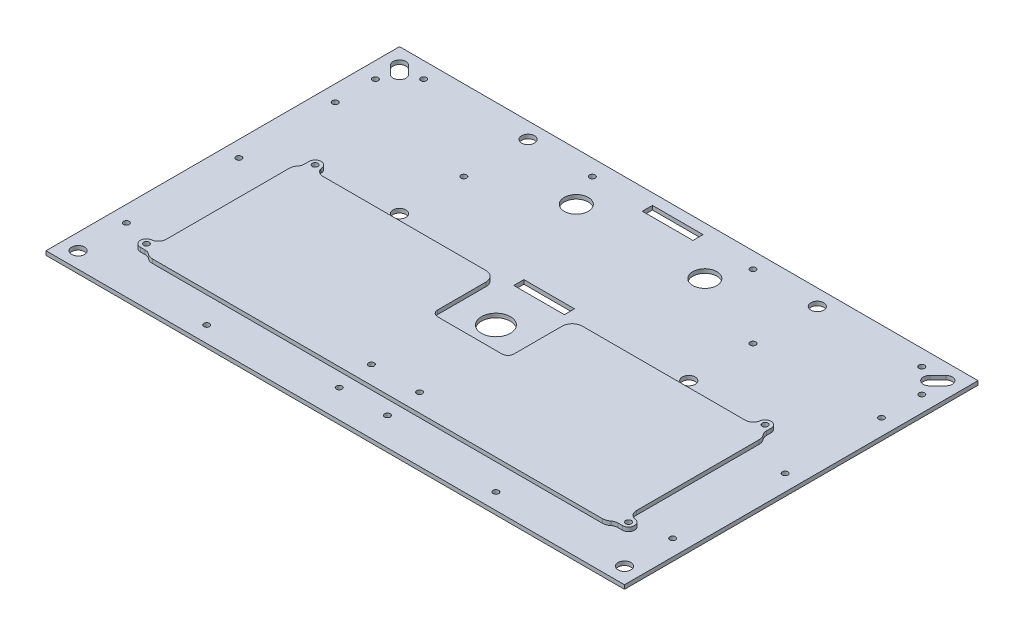
from build123d import *

# Parameters (mm, degrees)
SKETCH1_W           = 457.2
SKETCH1_H           = 279.4
BOSS_EXTRUDE1_DEPTH = 3.175
SKETCH2_R           = 5.08
SKETCH2_R_2         = 11.43
SKETCH2_W           = 8
SKETCH2_H           = 8
CUT_EXTRUDE1_DEPTH  = 3.175
SKETCH3_W           = 40
SKETCH3_H           = 8
CUT_EXTRUDE2_DEPTH  = 25.4
SKETCH4_R           = 2.25
CUT_EXTRUDE3_DEPTH  = 25.4
SKETCH5_R           = 9.525
CUT_EXTRUDE4_DEPTH  = 101.6
SKETCH6_R           = 2.25
CUT_EXTRUDE5_DEPTH  = 637.032
SKETCH7_W           = 190.5
SKETCH7_H           = 69.85
SKETCH7_W_2         = 63.5
SKETCH7_H_2         = 50.8
SKETCH7_R           = 2.25
CUT_EXTRUDE6_DEPTH  = 25.4
FILLET1_R           = 6.35
SKETCH8_R           = 2.25
BOSS_EXTRUDE2_DEPTH = 3.175
SKETCH9_R           = 2.25
BOSS_EXTRUDE3_DEPTH = 3.175


with BuildPart() as part:
    # Sketch1 → Boss-Extrude1 (new body)
    with BuildSketch(Plane(origin=(0, 0, 0), x_dir=(1, 0, 0), z_dir=(0, 1, 0))):
        Rectangle(SKETCH1_W, SKETCH1_H)
    extrude(amount=BOSS_EXTRUDE1_DEPTH)

    # Sketch2 → Cut-Extrude1 (cut)
    with BuildSketch(Plane(origin=(0, 3.175, 0), x_dir=(1, 0, 0), z_dir=(0, 1, 0))):
        with Locations((-114.3, 127)):
            Circle(SKETCH2_R)
        with Locations((114.3, 127)):
            Circle(SKETCH2_R)
        with Locations((-215.9, -127)):
            Circle(SKETCH2_R)
        with Locations((215.9, -127)):
            Circle(SKETCH2_R)
        with Locations((114.3, 25.4)):
            Circle(SKETCH2_R)
        with Locations((-114.3, 25.4)):
            Circle(SKETCH2_R)
        with Locations((0, -12.7)):
            Circle(SKETCH2_R_2)
        with BuildLine():
            Line((-212.307897552, 130.592102448), (-205.957897552, 124.242102448))
            ThreePointArc((-205.957897552, 124.242102448), (-205.957897552, 117.057897552), (-213.142102448, 117.057897552))
            Line((-213.142102448, 117.057897552), (-219.492102448, 123.407897552))
            ThreePointArc((-219.492102448, 123.407897552), (-219.492102448, 130.592102448), (-212.307897552, 130.592102448))
        make_face()
        with BuildLine():
            Line((212.307897552, 130.592102448), (205.957897552, 124.242102448))
            ThreePointArc((205.957897552, 124.242102448), (205.957897552, 117.057897552), (213.142102448, 117.057897552))
            Line((213.142102448, 117.057897552), (219.492102448, 123.407897552))
            ThreePointArc((219.492102448, 123.407897552), (219.492102448, 130.592102448), (212.307897552, 130.592102448))
        make_face()
        with Locations((-16, 127)):
            Rectangle(SKETCH2_W, SKETCH2_H)
        with Locations((16, 127)):
            Rectangle(SKETCH2_W, SKETCH2_H)
        with Locations((16, 25.4)):
            Rectangle(SKETCH2_W, SKETCH2_H)
        with Locations((-16, 25.4)):
            Rectangle(SKETCH2_W, SKETCH2_H)
    extrude(amount=-CUT_EXTRUDE1_DEPTH, mode=Mode.SUBTRACT)

    # Sketch3 → Cut-Extrude2 (cut)
    with BuildSketch(Plane(origin=(0, 3.175, 0), x_dir=(1, 0, 0), z_dir=(0, 1, 0))):
        with Locations((0, 127)):
            Rectangle(SKETCH3_W, SKETCH3_H)
        with Locations((0, 25.4)):
            Rectangle(SKETCH3_W, SKETCH3_H)
    extrude(amount=-CUT_EXTRUDE2_DEPTH, mode=Mode.SUBTRACT)

    # Sketch4 → Cut-Extrude3 (cut)
    with BuildSketch(Plane(origin=(0, 3.175, 0), x_dir=(1, 0, 0), z_dir=(0, 1, 0))):
        with Locations((-196.85, 127)):
            Circle(SKETCH4_R)
        with Locations((-215.9, 107.95)):
            Circle(SKETCH4_R)
        with Locations((196.85, 127)):
            Circle(SKETCH4_R)
        with Locations((215.9, 107.95)):
            Circle(SKETCH4_R)
    extrude(amount=-CUT_EXTRUDE3_DEPTH, mode=Mode.SUBTRACT)

    # Sketch5 → Cut-Extrude4 (cut)
    with BuildSketch(Plane(origin=(0, 3.175, 0), x_dir=(1, 0, 0), z_dir=(0, 1, 0))):
        with Locations((-50.8, 101.6)):
            Circle(SKETCH5_R)
        with Locations((50.8, 101.6)):
            Circle(SKETCH5_R)
    extrude(amount=-CUT_EXTRUDE4_DEPTH, mode=Mode.SUBTRACT)

    # Sketch6 → Cut-Extrude5 (cut)
    with BuildSketch(Plane(origin=(0, 3.175, 0), x_dir=(1, 0, 0), z_dir=(0, 1, 0))):
        with Locations((-215.9, 76.2)):
            Circle(SKETCH6_R)
        with Locations((-215.9, 0)):
            Circle(SKETCH6_R)
        with Locations((-215.9, -88.9)):
            Circle(SKETCH6_R)
        with Locations((-114.3, -76.2)):
            Circle(SKETCH6_R)
        with Locations((-114.3, 76.2)):
            Circle(SKETCH6_R)
        with Locations((-63.5, 127)):
            Circle(SKETCH6_R)
        with Locations((63.5, 127)):
            Circle(SKETCH6_R)
        with Locations((114.3, 76.2)):
            Circle(SKETCH6_R)
        with Locations((215.9, -88.9)):
            Circle(SKETCH6_R)
        with Locations((215.9, 0)):
            Circle(SKETCH6_R)
        with Locations((215.9, 76.2)):
            Circle(SKETCH6_R)
    extrude(amount=-CUT_EXTRUDE5_DEPTH, mode=Mode.SUBTRACT)

    # Sketch7 → Cut-Extrude6 (cut)
    with BuildSketch(Plane(origin=(0, 3.175, 0), x_dir=(1, 0, 0), z_dir=(0, 1, 0))):
        with Locations((0, -69.85)):
            Rectangle(SKETCH7_W, SKETCH7_H)
        with Locations((-63.5, -9.525)):
            Rectangle(SKETCH7_W_2, SKETCH7_H_2)
        with Locations((63.5, -9.525)):
            Rectangle(SKETCH7_W_2, SKETCH7_H_2)
        Polygon((-95.25, 15.875), (-184.15, 15.875), (-184.15, -104.775), (-95.25, -104.775), (-95.25, -34.925), align=None)
        with Locations((-114.3, -76.2)):
            Circle(SKETCH7_R, mode=Mode.SUBTRACT)
        Polygon((184.15, 15.875), (184.15, -104.775), (95.25, -104.775), (95.25, -34.925), (95.25, 15.875), align=None)
        with Locations((-19.05, -117.475)):
            Circle(SKETCH7_R)
        with Locations((19.05, -117.475)):
            Circle(SKETCH7_R)
        with Locations((114.3, -127)):
            Circle(SKETCH7_R)
        with Locations((-190.5, -98.425)):
            Circle(SKETCH7_R)
        with Locations((-177.8, 22.225)):
            Circle(SKETCH7_R)
        with Locations((190.5, -98.425)):
            Circle(SKETCH7_R)
        with Locations((-114.3, -127)):
            Circle(SKETCH7_R)
        with Locations((177.8, 22.225)):
            Circle(SKETCH7_R)
    extrude(amount=-CUT_EXTRUDE6_DEPTH, mode=Mode.SUBTRACT)

    # Fillet1
    fillet1_edges = [part.edges().sort_by_distance(p)[0] for p in [
        (-184.15, 1.5875, -15.875),
        (-31.75, 1.5875, -15.875),
        (-31.75, 1.5875, 34.925),
        (31.75, 1.5875, 34.925),
        (31.75, 1.5875, -15.875),
        (184.15, 1.5875, -15.875),
        (184.15, 1.5875, 104.775),
        (-184.15, 1.5875, 104.775),
    ]]
    fillet(fillet1_edges, radius=FILLET1_R)


with BuildPart() as body_2:
    # Sketch8 → Boss-Extrude2 (new body)
    with BuildSketch(Plane(origin=(0, 3.175, 0), x_dir=(1, 0, 0), z_dir=(0, 1, 0))):
        with BuildLine():
            Line((-38.1, 17.4625), (-177.8, 17.4625))
            ThreePointArc((-177.8, 17.4625), (-183.412660076, 15.137660076), (-185.7375, 9.525))
            Line((-185.7375, 9.525), (-185.7375, -98.425))
            ThreePointArc((-185.7375, -98.425), (-183.412660076, -104.037660076), (-177.8, -106.3625))
            Line((-177.8, -106.3625), (177.8, -106.3625))
            ThreePointArc((177.8, -106.3625), (183.412660076, -104.037660076), (185.7375, -98.425))
            Line((185.7375, -98.425), (185.7375, 9.525))
            ThreePointArc((185.7375, 9.525), (183.412660076, 15.137660076), (177.8, 17.4625))
            Line((177.8, 17.4625), (38.1, 17.4625))
            ThreePointArc((38.1, 17.4625), (32.487339924, 15.137660076), (30.1625, 9.525))
            Line((30.1625, 9.525), (30.1625, -28.575))
            ThreePointArc((30.1625, -28.575), (28.767596045, -31.942596045), (25.4, -33.3375))
            Line((25.4, -33.3375), (-25.4, -33.3375))
            ThreePointArc((-25.4, -33.3375), (-28.767596045, -31.942596045), (-30.1625, -28.575))
            Line((-30.1625, -28.575), (-30.1625, 9.525))
            ThreePointArc((-30.1625, 9.525), (-32.487339924, 15.137660076), (-38.1, 17.4625))
        make_face()
        with Locations((-19.05, -92.075)):
            Circle(SKETCH8_R, mode=Mode.SUBTRACT)
        with Locations((19.05, -92.075)):
            Circle(SKETCH8_R, mode=Mode.SUBTRACT)
    extrude(amount=BOSS_EXTRUDE2_DEPTH)

    # Sketch9 → Boss-Extrude3 (add)
    with BuildSketch(Plane(origin=(0, 6.35, 0), x_dir=(1, 0, 0), z_dir=(0, 1, 0))):
        with BuildLine():
            ThreePointArc((-173.0375, 22.225), (-177.8, 26.9875), (-182.5625, 22.225))
            Line((-182.5625, 22.225), (-182.5625, 18.505256121))
            ThreePointArc((-182.5625, 18.505256121), (-182.925662586, 16.388589454), (-183.973611111, 14.514031178))
            ThreePointArc((-183.973611111, 14.514031178), (-181.220779975, 16.687553359), (-177.8, 17.4625))
            Line((-177.8, 17.4625), (-166.889138938, 17.4625))
            ThreePointArc((-166.889138938, 17.4625), (-170.777703905, 18.792384214), (-173.0375, 22.225))
        make_face()
        with Locations((-177.8, 22.225)):
            Circle(SKETCH9_R, mode=Mode.SUBTRACT)
        with BuildLine():
            Line((-185.7375, -98.425), (-185.7375, -87.514138938))
            ThreePointArc((-185.7375, -87.514138938), (-187.067384214, -91.402703905), (-190.5, -93.6625))
            ThreePointArc((-190.5, -93.6625), (-195.2625, -98.425), (-190.5, -103.1875))
            Line((-190.5, -103.1875), (-186.780256121, -103.1875))
            ThreePointArc((-186.780256121, -103.1875), (-184.663589454, -103.550662586), (-182.789031178, -104.598611111))
            ThreePointArc((-182.789031178, -104.598611111), (-184.962553359, -101.845779975), (-185.7375, -98.425))
        make_face()
        with Locations((-190.5, -98.425)):
            Circle(SKETCH9_R, mode=Mode.SUBTRACT)
        with BuildLine():
            ThreePointArc((185.7375, -98.425), (184.962553359, -101.845779975), (182.789031178, -104.598611111))
            ThreePointArc((182.789031178, -104.598611111), (184.663589454, -103.550662586), (186.780256121, -103.1875))
            Line((186.780256121, -103.1875), (190.5, -103.1875))
            ThreePointArc((190.5, -103.1875), (195.2625, -98.425), (190.5, -93.6625))
            ThreePointArc((190.5, -93.6625), (187.067384214, -91.402703905), (185.7375, -87.514138938))
            Line((185.7375, -87.514138938), (185.7375, -98.425))
        make_face()
        with Locations((190.5, -98.425)):
            Circle(SKETCH9_R, mode=Mode.SUBTRACT)
        with BuildLine():
            ThreePointArc((173.0375, 22.225), (170.777703905, 18.792384214), (166.889138938, 17.4625))
            Line((166.889138938, 17.4625), (177.8, 17.4625))
            ThreePointArc((177.8, 17.4625), (181.220779975, 16.687553359), (183.973611111, 14.514031178))
            ThreePointArc((183.973611111, 14.514031178), (182.925662586, 16.388589454), (182.5625, 18.505256121))
            Line((182.5625, 18.505256121), (182.5625, 22.225))
            ThreePointArc((182.5625, 22.225), (177.8, 26.9875), (173.0375, 22.225))
        make_face()
        with Locations((177.8, 22.225)):
            Circle(SKETCH9_R, mode=Mode.SUBTRACT)
    extrude(amount=-BOSS_EXTRUDE3_DEPTH)


solid = Compound([part.part, body_2.part])
